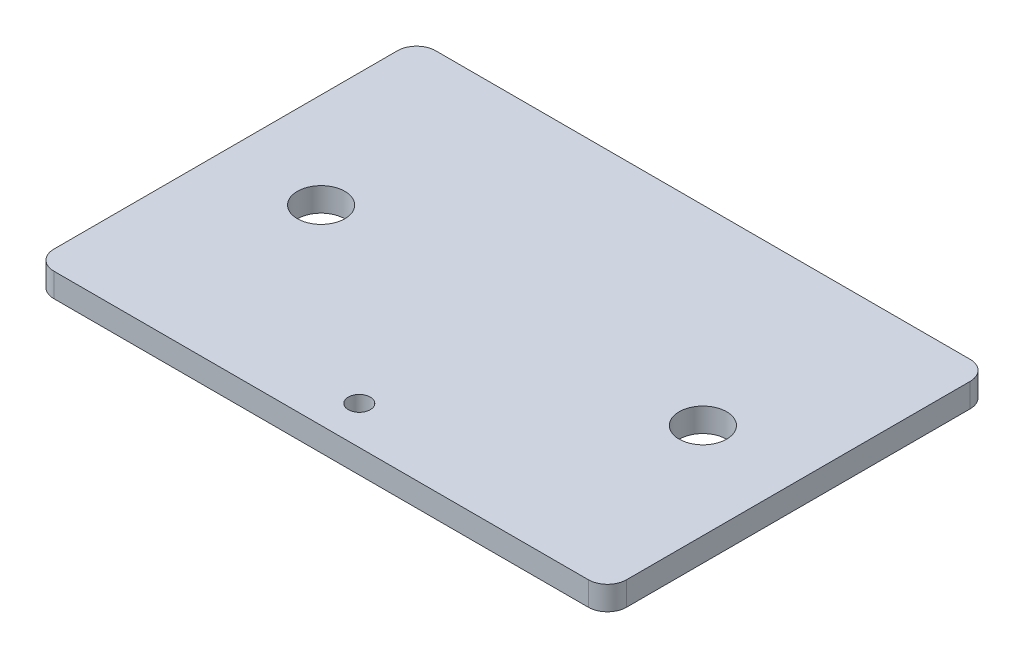
from build123d import *

# Parameters (mm, degrees)
SKETCH1_W           = 76.2
SKETCH1_H           = 50.8
SKETCH1_R           = 3.1623
SKETCH1_R_2         = 1.4605
BOSS_EXTRUDE1_DEPTH = 1.5875
FILLET1_R           = 2.54


with BuildPart() as part:
    # Sketch1 → Boss-Extrude1 (new body, symmetric)
    with BuildSketch(Plane(origin=(0, 0, 0), x_dir=(1, 0, 0), z_dir=(0, 1, 0))):
        Rectangle(SKETCH1_W, SKETCH1_H)
        with Locations((-25.4, 0)):
            Circle(SKETCH1_R, mode=Mode.SUBTRACT)
        with Locations((25.4, 0)):
            Circle(SKETCH1_R, mode=Mode.SUBTRACT)
        with Locations((0, -20.32)):
            Circle(SKETCH1_R_2, mode=Mode.SUBTRACT)
    extrude(amount=BOSS_EXTRUDE1_DEPTH, both=True)

    # Fillet1
    fillet1_edges = [part.edges().sort_by_distance(p)[0] for p in [
        (-38.1, 0, -25.4),
        (38.1, 0, -25.4),
        (38.1, 0, 25.4),
        (-38.1, 0, 25.4),
    ]]
    fillet(fillet1_edges, radius=FILLET1_R)


solid = part.part
